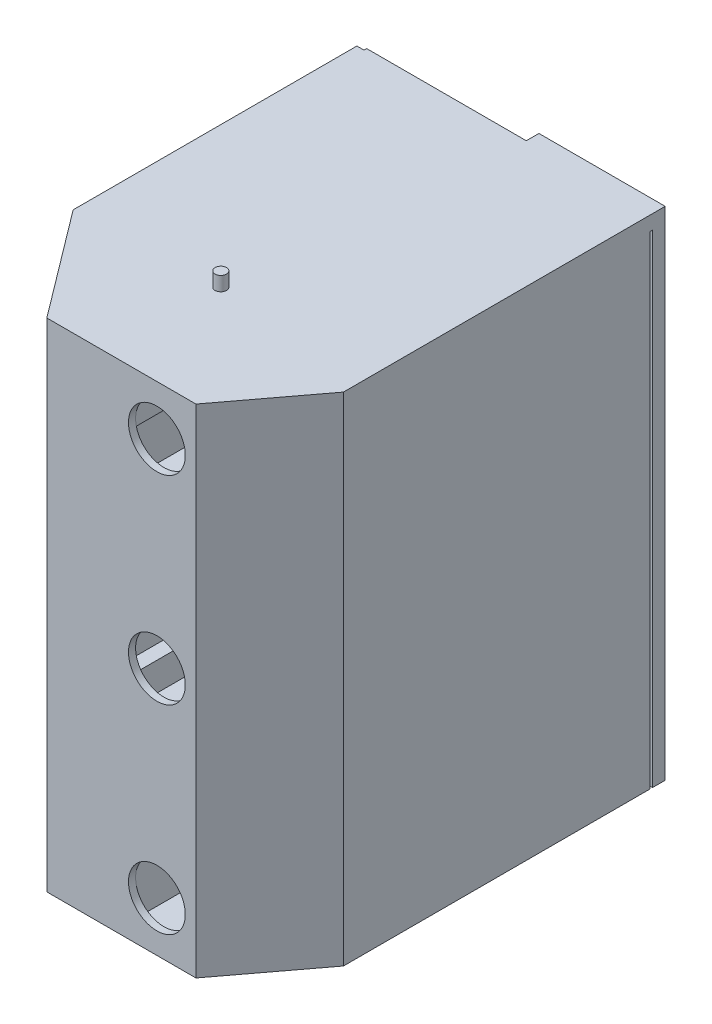
from build123d import *

# Parameters (mm, degrees)
EXTRUDE_THIN1_DEPTH       = 350
SKETCH5_W                 = 10
SKETCH5_H                 = 250
EXTRUDE_THIN3_DEPTH       = 350
SKETCH8_W                 = 150
SKETCH8_H                 = 50
CUT_EXTRUDE2_DEPTH        = 20
LPATTERN4_COUNT           = 2
LPATTERN4_PITCH           = 100
LPATTERN5_COUNT           = 2
LPATTERN5_PITCH           = 100
BOSS_EXTRUDE1_DEPTH       = 10
BOSS_EXTRUDE2_DEPTH       = 10
SKETCH12_R                = 20
CUT_EXTRUDE3_DEPTH        = 5
SKETCH13_W                = 45
SKETCH13_H                = 5
EXTRUDE_THIN4_DEPTH       = 45
BOSS_EXTRUDE4_DEPTH       = 5
LPATTERN6_COUNT           = 2
LPATTERN6_PITCH           = 140
SKETCH16_R                = 4
BOSS_EXTRUDE13_DEPTH      = 10
BOSS_EXTRUDE13_DEPTH_BACK = 380
SCALE2_SCALE              = 0.5625
SKETCH18_W                = 50
SKETCH18_H                = 196.875
BOSS_EXTRUDE14_DEPTH      = 5
CUT_EXTRUDE4_DEPTH        = 1


with BuildPart() as part:
    # Sketch1 → Extrude-Thin1 (new body)
    with BuildSketch(Plane(origin=(0, 0, 0), x_dir=(1, 0, 0), z_dir=(0, 1, 0))):
        Polygon((-104.163352084, 270), (-104.163352084, 71.877195904), (-50, 0), (50, 0), (92.127051621, 55.904485703), (92.127051621, 270), (97.127051621, 270), (97.127051621, 54.231509106), (52.49290804, -5), (-52.49290804, -5), (-109.163352084, 70.204219307), (-109.163352084, 270), align=None)
    extrude(amount=EXTRUDE_THIN1_DEPTH)

    # Sketch5 → Extrude-Thin3 (add)
    with BuildSketch(Plane.XZ):
        with Locations((0, -125)):
            Rectangle(SKETCH5_W, SKETCH5_H)
    extrude(amount=-EXTRUDE_THIN3_DEPTH)

    # Sketch8 → Cut-Extrude2 (cut)
    with BuildSketch(Plane(origin=(5, 0, 0), x_dir=(0, 0, -1), z_dir=(1, 0, 0))):
        with Locations((75, 185)):
            Rectangle(SKETCH8_W, SKETCH8_H)
    cut_extrude2 = extrude(amount=-CUT_EXTRUDE2_DEPTH, mode=Mode.SUBTRACT)

    # LPattern4: Cut-Extrude2 ×2
    with Locations(*[(0, i * LPATTERN4_PITCH, 0) for i in range(1, LPATTERN4_COUNT)]):
        add(cut_extrude2, mode=Mode.SUBTRACT)

    # LPattern5: Cut-Extrude2 ×2
    with Locations(*[(0, -i * LPATTERN5_PITCH, 0) for i in range(1, LPATTERN5_COUNT)]):
        add(cut_extrude2, mode=Mode.SUBTRACT)

    # Sketch9 → Boss-Extrude1 (add)
    with BuildSketch(Plane(origin=(0, 0, 0), x_dir=(-1, 0, 0), z_dir=(0, -1, 0))):
        Polygon((104.163352084, 270), (104.163352084, 71.877195904), (50, 0), (-50, 0), (-92.127051621, 55.904485703), (-92.127051621, 270), align=None)
    extrude(amount=-BOSS_EXTRUDE1_DEPTH)

    # Sketch10 → Boss-Extrude2 (add)
    with BuildSketch(Plane(origin=(0, 350, 0), x_dir=(1, 0, 0), z_dir=(0, 1, 0))):
        Polygon((97.127051621, 271.877195904), (97.127051621, 54.231509106), (50, 0), (-50, 0), (-104.163352084, 71.877195904), (-104.163352084, 271.877195904), align=None)
    extrude(amount=-BOSS_EXTRUDE2_DEPTH)

    # Sketch12 → Cut-Extrude3 (cut)
    with BuildSketch(Plane(origin=(0, 0, 0), x_dir=(-1, 0, 0), z_dir=(0, 0, -1))):
        with Locations((-25, 35)):
            Circle(SKETCH12_R)
        with Locations((-25, 175)):
            Circle(SKETCH12_R)
        with Locations((-25, 315)):
            Circle(SKETCH12_R)
    extrude(amount=-CUT_EXTRUDE3_DEPTH, mode=Mode.SUBTRACT)

    # Sketch13 → Extrude-Thin4 (add)
    with BuildSketch(Plane(origin=(0, 0, 0), x_dir=(-1, 0, 0), z_dir=(0, 0, -1))):
        with Locations((-27.5, 137.5)):
            Rectangle(SKETCH13_W, SKETCH13_H)
    extrude_thin4 = extrude(amount=EXTRUDE_THIN4_DEPTH)

    # Sketch15 → Boss-Extrude4 (add)
    with BuildSketch(Plane(origin=(0, 140, 0), x_dir=(1, 0, 0), z_dir=(0, 1, 0))):
        Polygon((50, 0), (50, 45), (85.745079967, 45), align=None)
    boss_extrude4 = extrude(amount=-BOSS_EXTRUDE4_DEPTH)

    # LPattern6: Extrude-Thin4, Boss-Extrude4 ×2
    with Locations(*[(0, i * LPATTERN6_PITCH, 0) for i in range(1, LPATTERN6_COUNT)]):
        add(extrude_thin4)
        add(boss_extrude4)

    # Sketch16 → Boss-Extrude13 (add, two sides)
    with BuildSketch(Plane(origin=(0, 350, 0), x_dir=(1, 0, 0), z_dir=(0, 1, 0))) as boss_extrude13_sk:
        with Locations((-10, 75)):
            Circle(SKETCH16_R)
    extrude(amount=BOSS_EXTRUDE13_DEPTH)
    extrude(boss_extrude13_sk.sketch, amount=-BOSS_EXTRUDE13_DEPTH_BACK)


with BuildPart() as part_1:
    # Scale2: scaled about (-3.397315278, 174.681693156, -127.670215341)
    add(part.part.scale(SCALE2_SCALE).moved(Location((-1.486325434, 76.423240756, -55.855719212))))

    # Sketch18 → Boss-Extrude14 (add)
    with BuildSketch(Plane(origin=(0, 0, -208.786641908), x_dir=(-1, 0, 0), z_dir=(0, 0, -1))):
        with Locations((-28.147641103, 174.860740756)):
            Rectangle(SKETCH18_W, SKETCH18_H)
    extrude(amount=BOSS_EXTRUDE14_DEPTH)

    # Sketch19 → Cut-Extrude4 (cut)
    with BuildSketch(Plane(origin=(0, 0, -213.786641908), x_dir=(-1, 0, 0), z_dir=(0, 0, -1))):
        Polygon((-18.147641103, 262.913625371), (-18.147641103, 264.259779217), (-12.43550168, 264.259779217), (-18.147641103, 270.512784025), (-18.147641103, 272.43285614), (-11.416871872, 265.062062871), (-3.147641103, 273.009779217), (-3.147641103, 271.215909025), (-10.386222833, 264.259779217), (-3.147641103, 264.259779217), (-3.147641103, 262.913625371), align=None)
        Polygon((-3.147641103, 247.529009986), (-18.147641103, 247.529009986), (-18.147641103, 247.811461909), (-6.34175168, 257.721317679), (-18.147641103, 257.721317679), (-18.147641103, 259.067471525), (-3.147641103, 259.067471525), (-3.147641103, 258.76098114), (-14.926487257, 248.875163833), (-3.147641103, 248.875163833), align=None)
        Polygon((-18.147641103, 238.298240756), (-3.147641103, 245.221317679), (-3.147641103, 243.757976333), (-7.95533341, 241.540428256), (-7.95533341, 234.740548448), (-3.147641103, 232.459899409), (-3.147641103, 230.990548448), (-18.147641103, 238.105933063), align=None)
        Polygon((-15.223963218, 238.187062871), (-9.493794949, 235.470716717), (-9.493794949, 240.83129364), align=None, mode=Mode.SUBTRACT)
        Polygon((-16.609179564, 221.567471525), (-18.147641103, 221.567471525), (-18.147641103, 229.452086909), (-16.609179564, 229.452086909), (-16.609179564, 226.18285614), (-3.147641103, 226.18285614), (-3.147641103, 224.836702294), (-16.609179564, 224.836702294), align=None)
        with BuildLine():
            Line((-3.147641103, 202.144394602), (-18.147641103, 202.144394602))
            Line((-18.147641103, 202.144394602), (-18.147641103, 205.173240756))
            add(Edge.make_bspline(
                [(-18.147641103, 205.173240756), (-18.145744374, 205.436679277), (-18.142079904, 205.945641128), (-18.118845371, 206.681123045), (-18.077743374, 207.361624885), (-18.017873977, 207.984908566), (-17.944360976, 208.552685189), (-17.852216385, 209.063364938), (-17.743409941, 209.519588408), (-17.650643726, 209.800171725), (-17.606775718, 209.93285614)],
                knots=[0, 0, 0, 0, 0.000790316, 0.001526886, 0.002207274, 0.002835157, 0.003405034, 0.003924274, 0.004391423, 0.004810516, 0.004810516, 0.004810516, 0.004810516], degree=3))
            add(Edge.make_bspline(
                [(-17.606775718, 209.93285614), (-17.540664717, 210.106420653), (-17.409941893, 210.449613811), (-17.16297306, 210.937988863), (-16.884295991, 211.399306118), (-16.567497553, 211.829887547), (-16.216714601, 212.230813526), (-15.834453124, 212.606634445), (-15.412221348, 212.948084436), (-14.957534749, 213.260481583), (-14.476219142, 213.542224169), (-13.969062798, 213.787101322), (-13.43867636, 213.990476925), (-12.886525289, 214.15930467), (-12.311398076, 214.292361019), (-11.712624331, 214.383140697), (-11.092570671, 214.443016376), (-10.671822968, 214.449033738), (-10.458338218, 214.452086909)],
                knots=[0, 0, 0, 0, 0.000556863, 0.001101098, 0.001639102, 0.002172182, 0.002702469, 0.003235812, 0.00377831, 0.00432924, 0.004889433, 0.005449852, 0.006016798, 0.006591848, 0.007180798, 0.007785966, 0.008407584, 0.009047862, 0.009047862, 0.009047862, 0.009047862], degree=3))
            add(Edge.make_bspline(
                [(-10.458338218, 214.452086909), (-10.272932912, 214.449391332), (-9.907572391, 214.444079416), (-9.369111386, 214.396382378), (-8.84662474, 214.327055183), (-8.34259999, 214.219723303), (-7.852623079, 214.089425379), (-7.381909188, 213.922441429), (-6.926165668, 213.731127128), (-6.491461742, 213.50812726), (-6.079885114, 213.262977531), (-5.691609818, 213.001532699), (-5.33525181, 212.717863399), (-5.001472896, 212.420365381), (-4.699189603, 212.101864524), (-4.422891713, 211.766238529), (-4.177205051, 211.412183063), (-3.95826889, 211.037506421), (-3.762480338, 210.637204704), (-3.599169195, 210.198686395), (-3.457725073, 209.724028667), (-3.345206266, 209.210524668), (-3.254459043, 208.66000591), (-3.194039191, 208.07094524), (-3.153063119, 207.444455901), (-3.149483535, 207.014257563), (-3.147641103, 206.792832102)],
                knots=[0, 0, 0, 0, 0.000556092, 0.001095838, 0.001620648, 0.002136295, 0.002640709, 0.003140574, 0.003633371, 0.004122528, 0.004604872, 0.005069919, 0.005525591, 0.005970272, 0.006410217, 0.006841509, 0.007273282, 0.007701538, 0.008142335, 0.008608322, 0.009103642, 0.009627065, 0.010184285, 0.010776598, 0.011402817, 0.012066988, 0.012066988, 0.012066988, 0.012066988], degree=3))
            Line((-3.147641103, 206.792832102), (-3.147641103, 202.144394602))
        make_face()
        with BuildLine():
            Line((-4.686102641, 203.490548448), (-4.686102641, 205.212303256))
            add(Edge.make_bspline(
                [(-4.686102641, 205.212303256), (-4.687165911, 205.459710559), (-4.689210969, 205.935565409), (-4.707156126, 206.619813969), (-4.736478715, 207.245011382), (-4.777514763, 207.811246423), (-4.831808828, 208.318199384), (-4.892344125, 208.766929741), (-4.967761771, 209.155966562), (-5.036123026, 209.391378435), (-5.067713218, 209.500163833)],
                knots=[0, 0, 0, 0, 0.000742212, 0.001427545, 0.002053267, 0.002619735, 0.00313042, 0.003582561, 0.003977976, 0.004317679, 0.004317679, 0.004317679, 0.004317679], degree=3))
            add(Edge.make_bspline(
                [(-5.067713218, 209.500163833), (-5.115934173, 209.637085399), (-5.211224326, 209.907658162), (-5.385043004, 210.297148321), (-5.59093711, 210.660393385), (-5.819805751, 211.003719291), (-6.079710645, 211.322272454), (-6.365039456, 211.619765497), (-6.677095783, 211.895834201), (-7.015373615, 212.146226361), (-7.376204735, 212.373024032), (-7.760227301, 212.567720319), (-8.162042536, 212.737275278), (-8.584903362, 212.8715321), (-9.025710434, 212.977387722), (-9.486749528, 213.051586596), (-9.967612674, 213.097650377), (-10.294971818, 213.103142065), (-10.461343026, 213.105933063)],
                knots=[0, 0, 0, 0, 0.000435397, 0.000860394, 0.001277456, 0.001686651, 0.002096804, 0.002509088, 0.002922071, 0.003345152, 0.003770361, 0.00419905, 0.00463544, 0.005077311, 0.005528442, 0.005994275, 0.006477152, 0.006976176, 0.006976176, 0.006976176, 0.006976176], degree=3))
            add(Edge.make_bspline(
                [(-10.461343026, 213.105933063), (-10.636772227, 213.10373326), (-10.981404446, 213.099411728), (-11.487078854, 213.045093255), (-11.973424499, 212.96571516), (-12.440473908, 212.850927934), (-12.889138274, 212.704652739), (-13.316936175, 212.522104274), (-13.728385613, 212.313533049), (-14.113990038, 212.065375891), (-14.478674791, 211.793594776), (-14.812767287, 211.491975293), (-15.117028574, 211.165309414), (-15.396197056, 210.817160059), (-15.639041382, 210.437715348), (-15.856270015, 210.035913816), (-16.040623835, 209.60586094), (-16.138676104, 209.306663672), (-16.188506487, 209.154610948)],
                knots=[0, 0, 0, 0, 0.000526056, 0.001033442, 0.001523971, 0.002003509, 0.002474814, 0.002938022, 0.00339763, 0.003856933, 0.004311862, 0.004760786, 0.005205102, 0.005649976, 0.006097541, 0.006554627, 0.007019013, 0.00749889, 0.00749889, 0.00749889, 0.00749889], degree=3))
            add(Edge.make_bspline(
                [(-16.188506487, 209.154610948), (-16.223291178, 209.028820321), (-16.297252975, 208.761354934), (-16.377933143, 208.324900088), (-16.449095281, 207.833692305), (-16.509344022, 207.285550728), (-16.552575399, 206.681100189), (-16.58502389, 206.019875812), (-16.606909458, 205.301591793), (-16.608403917, 204.803666648), (-16.609179564, 204.545235948)],
                knots=[0, 0, 0, 0, 0.000391375, 0.000832172, 0.001330209, 0.001880376, 0.002486022, 0.003147905, 0.003866362, 0.004641626, 0.004641626, 0.004641626, 0.004641626], degree=3))
            Line((-16.609179564, 204.545235948), (-16.609179564, 203.490548448))
            Line((-16.609179564, 203.490548448), (-4.686102641, 203.490548448))
        make_face(mode=Mode.SUBTRACT)
        Polygon((-18.147641103, 190.990548448), (-18.147641103, 199.452086909), (-16.609179564, 199.452086909), (-16.609179564, 192.336702294), (-11.993794949, 192.336702294), (-11.993794949, 199.452086909), (-10.45533341, 199.452086909), (-10.45533341, 192.336702294), (-4.686102641, 192.336702294), (-4.686102641, 199.452086909), (-3.147641103, 199.452086909), (-3.147641103, 190.990548448), align=None)
        Polygon((-18.147641103, 179.836702294), (-18.147641103, 188.298240756), (-16.609179564, 188.298240756), (-16.609179564, 181.18285614), (-11.993794949, 181.18285614), (-11.993794949, 188.298240756), (-10.45533341, 188.298240756), (-10.45533341, 181.18285614), (-4.686102641, 181.18285614), (-4.686102641, 188.298240756), (-3.147641103, 188.298240756), (-3.147641103, 179.836702294), align=None)
        with BuildLine():
            Line((-6.04127091, 167.913625371), (-6.801487257, 169.181654217))
            add(Edge.make_bspline(
                [(-6.801487257, 169.181654217), (-6.604068464, 169.29958952), (-6.225821676, 169.525549008), (-5.714715788, 169.902483404), (-5.280306545, 170.293053024), (-4.925121084, 170.700150168), (-4.645482998, 171.121289945), (-4.447473433, 171.559221604), (-4.323976396, 172.012469364), (-4.308976025, 172.320928599), (-4.301487257, 172.474923448)],
                knots=[0, 0, 0, 0, 0.000689576, 0.0013212, 0.001901906, 0.0024387, 0.002937914, 0.003412645, 0.003875444, 0.004336836, 0.004336836, 0.004336836, 0.004336836], degree=3))
            add(Edge.make_bspline(
                [(-4.301487257, 172.474923448), (-4.30523728, 172.606411939), (-4.312671712, 172.867088183), (-4.38122086, 173.25159775), (-4.493367125, 173.623164938), (-4.645393528, 173.978096133), (-4.832267029, 174.306987984), (-5.052625958, 174.600019), (-5.307242814, 174.847452627), (-5.586685243, 175.052578095), (-5.886341246, 175.211302692), (-6.195094191, 175.331268285), (-6.517180402, 175.398455479), (-6.734091072, 175.408537501), (-6.843554564, 175.413625371)],
                knots=[0, 0, 0, 0, 0.000394191, 0.000781485, 0.001167436, 0.001556463, 0.001937363, 0.002299751, 0.00265248, 0.00299866, 0.003336082, 0.003667021, 0.003989377, 0.004317782, 0.004317782, 0.004317782, 0.004317782], degree=3))
            add(Edge.make_bspline(
                [(-6.843554564, 175.413625371), (-6.968485604, 175.407442604), (-7.221484584, 175.394921826), (-7.595393514, 175.28457538), (-7.967017493, 175.116080974), (-8.196934162, 174.957715169), (-8.315910333, 174.875764794)],
                knots=[0, 0, 0, 0, 0.000374059, 0.000757511, 0.001160872, 0.00159345, 0.00159345, 0.00159345, 0.00159345], degree=3))
            add(Edge.make_bspline(
                [(-8.315910333, 174.875764794), (-8.401836154, 174.808614864), (-8.582226666, 174.667641987), (-8.850515518, 174.425079773), (-9.127815998, 174.141898602), (-9.420215824, 173.82197426), (-9.725286363, 173.464770096), (-10.045408228, 173.070147908), (-10.374039701, 172.634739822), (-10.594159213, 172.329128356), (-10.707737257, 172.171437871)],
                knots=[0, 0, 0, 0, 0.000327083, 0.000686669, 0.001083997, 0.001515739, 0.00198669, 0.002493042, 0.003039925, 0.003622928, 0.003622928, 0.003622928, 0.003622928], degree=3))
            add(Edge.make_bspline(
                [(-10.707737257, 172.171437871), (-10.820145489, 172.013620745), (-11.03506147, 171.711886416), (-11.354022687, 171.289921063), (-11.645639271, 170.912587651), (-11.912656466, 170.581563294), (-12.155110486, 170.296993593), (-12.370673082, 170.056636117), (-12.565174058, 169.86661373), (-12.691351237, 169.760946956), (-12.74800168, 169.713505179)],
                knots=[0, 0, 0, 0, 0.000581242, 0.00111129, 0.001586715, 0.002011882, 0.002387014, 0.002708191, 0.002980189, 0.003201812, 0.003201812, 0.003201812, 0.003201812], degree=3))
            add(Edge.make_bspline(
                [(-12.74800168, 169.713505179), (-12.83629622, 169.647205385), (-13.009939285, 169.516817943), (-13.281269077, 169.34451954), (-13.558490874, 169.199219828), (-13.842609387, 169.082280725), (-14.131489299, 168.987716503), (-14.427299404, 168.92197011), (-14.728031568, 168.881445423), (-14.930368138, 168.877259339), (-15.031655526, 168.875163833)],
                knots=[0, 0, 0, 0, 0.000331157, 0.000651264, 0.00096307, 0.001268867, 0.001571995, 0.001873795, 0.002176804, 0.002480528, 0.002480528, 0.002480528, 0.002480528], degree=3))
            add(Edge.make_bspline(
                [(-15.031655526, 168.875163833), (-15.19035487, 168.880757336), (-15.504361471, 168.891824787), (-15.963060528, 168.985430617), (-16.401019094, 169.133158125), (-16.813800365, 169.340186789), (-17.191033111, 169.606814867), (-17.536112784, 169.916711548), (-17.830170868, 170.282398074), (-18.083091717, 170.687240242), (-18.283102687, 171.128043524), (-18.428051335, 171.592113526), (-18.514149011, 172.076114363), (-18.526161356, 172.40446854), (-18.532256487, 172.571077294)],
                knots=[0, 0, 0, 0, 0.00047571, 0.000941251, 0.001398308, 0.00185923, 0.002321033, 0.002780464, 0.003246006, 0.00372377, 0.004209193, 0.00469389, 0.005179006, 0.005678708, 0.005678708, 0.005678708, 0.005678708], degree=3))
            add(Edge.make_bspline(
                [(-18.532256487, 172.571077294), (-18.526242621, 172.747866345), (-18.51428296, 173.099443341), (-18.407708897, 173.615767854), (-18.238091452, 174.114914766), (-18.039085752, 174.514665797), (-17.841591749, 174.828193227), (-17.661314853, 175.067057926), (-17.454202178, 175.310427289), (-17.215887472, 175.555685822), (-16.951137267, 175.805254738), (-16.657710433, 176.057984461), (-16.338251224, 176.316240111), (-16.110136466, 176.482327319), (-15.993193987, 176.567471525)],
                knots=[0, 0, 0, 0, 0.000529878, 0.001053758, 0.001574484, 0.00210797, 0.0023889, 0.002685175, 0.003004901, 0.00334704, 0.003710522, 0.004096087, 0.004508579, 0.00494248, 0.00494248, 0.00494248, 0.00494248], degree=3))
            Line((-15.993193987, 176.567471525), (-15.070718026, 175.350524409))
            add(Edge.make_bspline(
                [(-15.070718026, 175.350524409), (-15.16538932, 175.277047199), (-15.347704099, 175.135547271), (-15.60293686, 174.920635349), (-15.836397299, 174.718382633), (-16.038642556, 174.517589918), (-16.224817552, 174.333734256), (-16.381384692, 174.152122073), (-16.513290755, 173.979761809), (-16.654315889, 173.763023539), (-16.789880828, 173.4884658), (-16.908958692, 173.1466856), (-16.979602035, 172.788304196), (-16.989024771, 172.544341099), (-16.993794949, 172.420836909)],
                knots=[0, 0, 0, 0, 0.000359473, 0.000692262, 0.001000939, 0.001285683, 0.001547032, 0.001785607, 0.002004361, 0.002197722, 0.002560545, 0.002919743, 0.003280982, 0.003651355, 0.003651355, 0.003651355, 0.003651355], degree=3))
            add(Edge.make_bspline(
                [(-16.993794949, 172.420836909), (-16.988686982, 172.265843817), (-16.978836748, 171.96695424), (-16.868426575, 171.543607135), (-16.700555346, 171.160372361), (-16.458486784, 170.831879838), (-16.169894432, 170.560648657), (-15.84077518, 170.362015672), (-15.477275772, 170.243256502), (-15.223831553, 170.228720587), (-15.094756487, 170.221317679)],
                knots=[0, 0, 0, 0, 0.000463919, 0.000894625, 0.001303455, 0.001712153, 0.002109754, 0.002484392, 0.002856892, 0.003243486, 0.003243486, 0.003243486, 0.003243486], degree=3))
            add(Edge.make_bspline(
                [(-15.094756487, 170.221317679), (-15.014411436, 170.223098757), (-14.852602095, 170.226685724), (-14.6146802, 170.272521361), (-14.37801279, 170.33449491), (-14.143432812, 170.429503331), (-13.905628358, 170.561810426), (-13.661240636, 170.735368996), (-13.408164627, 170.95400834), (-13.243561185, 171.121479619), (-13.156655526, 171.209899409)],
                knots=[0, 0, 0, 0, 0.000240685, 0.000484723, 0.000724543, 0.00097396, 0.001241591, 0.001539203, 0.001871639, 0.002243471, 0.002243471, 0.002243471, 0.002243471], degree=3))
            add(Edge.make_bspline(
                [(-13.156655526, 171.209899409), (-13.127353987, 171.242733863), (-13.057740237, 171.320741008), (-12.94377332, 171.463352118), (-12.80319001, 171.651678396), (-12.629244368, 171.880802115), (-12.427466673, 172.154947951), (-12.200436906, 172.474146049), (-11.940784939, 172.834838333), (-11.759252622, 173.090789401), (-11.663266103, 173.226125371)],
                knots=[0, 0, 0, 0, 0.000132007, 0.000313617, 0.000547394, 0.000837058, 0.001176615, 0.001568532, 0.002012146, 0.002509902, 0.002509902, 0.002509902, 0.002509902], degree=3))
            add(Edge.make_bspline(
                [(-11.663266103, 173.226125371), (-11.544803049, 173.388922027), (-11.315415765, 173.704155189), (-10.970778269, 174.152689228), (-10.633712527, 174.559371657), (-10.306392946, 174.925660399), (-9.991229183, 175.25507335), (-9.684673878, 175.544289836), (-9.388737379, 175.794622101), (-9.011908432, 176.067803181), (-8.544815158, 176.343635091), (-7.972279837, 176.580138284), (-7.398101519, 176.730597565), (-7.012683364, 176.750138075), (-6.82252091, 176.759779217)],
                knots=[0, 0, 0, 0, 0.000603996, 0.001169555, 0.001696631, 0.002188218, 0.002642988, 0.003063875, 0.003452066, 0.003804872, 0.004459368, 0.005073739, 0.005658944, 0.006228884, 0.006228884, 0.006228884, 0.006228884], degree=3))
            add(Edge.make_bspline(
                [(-6.82252091, 176.759779217), (-6.688043627, 176.75696004), (-6.421700519, 176.751376433), (-6.030586617, 176.687299973), (-5.650817075, 176.593203312), (-5.287461742, 176.452520982), (-4.934690483, 176.278012998), (-4.599148823, 176.059753758), (-4.274317911, 175.805440432), (-3.969304442, 175.513862406), (-3.688957766, 175.194972388), (-3.440607024, 174.856714456), (-3.228761851, 174.502619719), (-3.060047944, 174.128853569), (-2.927205867, 173.739431245), (-2.831224647, 173.333068578), (-2.772251541, 172.909353929), (-2.766135324, 172.621350237), (-2.763025718, 172.474923448)],
                knots=[0, 0, 0, 0, 0.000403048, 0.000798268, 0.001185982, 0.001574951, 0.00196465, 0.00236473, 0.002773483, 0.003200684, 0.003628645, 0.00404574, 0.004458001, 0.004864095, 0.005273643, 0.005690532, 0.006115062, 0.006554134, 0.006554134, 0.006554134, 0.006554134], degree=3))
            add(Edge.make_bspline(
                [(-2.763025718, 172.474923448), (-2.765216497, 172.361629121), (-2.769570463, 172.136467293), (-2.808061661, 171.803426652), (-2.862520691, 171.477114143), (-2.948980938, 171.161624302), (-3.053882463, 170.852892765), (-3.183046013, 170.552260903), (-3.337836793, 170.259588208), (-3.514804821, 169.973214655), (-3.720808019, 169.693945337), (-3.960529242, 169.424096833), (-4.227855667, 169.156570184), (-4.526917033, 168.893263131), (-4.861001978, 168.639920206), (-5.225134171, 168.390459457), (-5.62039646, 168.146096618), (-5.898359077, 167.992563145), (-6.04127091, 167.913625371)],
                knots=[0, 0, 0, 0, 0.000339756, 0.000675233, 0.001004736, 0.001331266, 0.001655298, 0.001982381, 0.002311678, 0.002647706, 0.002991465, 0.003351302, 0.003729502, 0.004125522, 0.004545615, 0.004986514, 0.005449312, 0.00593905, 0.00593905, 0.00593905, 0.00593905], degree=3))
        make_face()
    extrude(amount=-CUT_EXTRUDE4_DEPTH, mode=Mode.SUBTRACT)


solid = part_1.part
